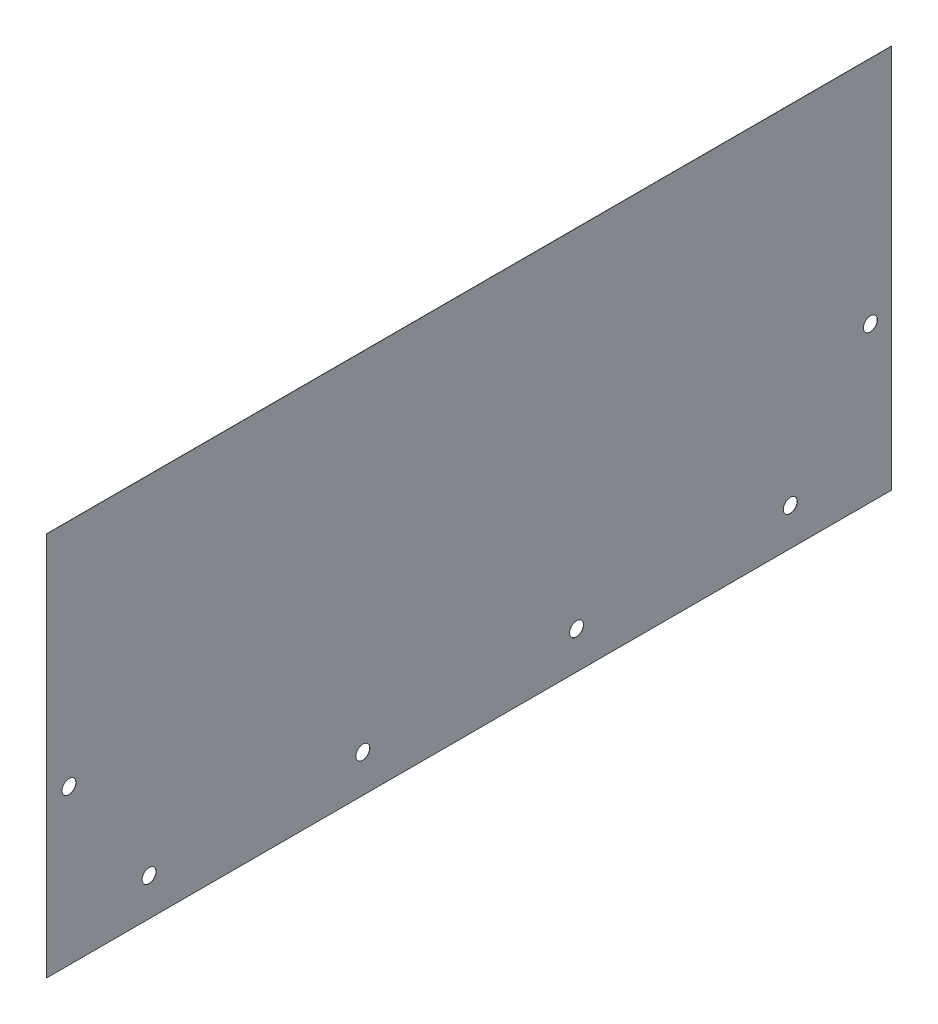
from build123d import *

# Parameters (mm, degrees)
SKETCH1_W                 = 502.3866
SKETCH1_H                 = 809.7266
SIDEPANEL_DEPTH           = 0.127
SKETCH2_R                 = 4.1656
TOPBOTTOMHOLEMASTER_DEPTH = 1.127
LPATTERN1_COUNT           = 4
LPATTERN1_PITCH           = 127.067733333
SKETCH3_R                 = 4.1656
REARHOLESMASTER_DEPTH     = 1.127
LPATTERN2_COUNT           = 4
LPATTERN2_PITCH           = 211.7344
SKETCH4_W                 = 502.3866
SKETCH4_H                 = 581.1266
CUT_EXTRUDE1_DEPTH        = 1.127


with BuildPart() as part:
    # Sketch1 → SidePanel (new body)
    with BuildSketch(Plane(origin=(0, 0, 0), x_dir=(0, 0, -1), z_dir=(1, 0, 0))):
        Rectangle(SKETCH1_W, SKETCH1_H)
    extrude(amount=SIDEPANEL_DEPTH)

    # Sketch2 → TopBottomHoleMaster (cut, through all)
    with BuildSketch(Plane(origin=(0.127, 0, 0), x_dir=(0, 0, -1), z_dir=(1, 0, 0))):
        with Locations((190.9699, -382.6383)):
            Circle(SKETCH2_R)
    topbottomholemaster = extrude(amount=-TOPBOTTOMHOLEMASTER_DEPTH, mode=Mode.SUBTRACT)

    # LPattern1: TopBottomHoleMaster ×4
    with Locations(*[(0, 0, i * LPATTERN1_PITCH) for i in range(1, LPATTERN1_COUNT)]):
        add(topbottomholemaster, mode=Mode.SUBTRACT)

    # Sketch3 → RearHolesMaster (cut, through all)
    with BuildSketch(Plane(origin=(0.127, 0, 0), x_dir=(0, 0, -1), z_dir=(1, 0, 0))):
        with Locations((-237.8583, 322.2117)):
            Circle(SKETCH3_R)
        with Locations((238.5949, 322.2117)):
            Circle(SKETCH3_R)
    rearholesmaster = extrude(amount=-REARHOLESMASTER_DEPTH, mode=Mode.SUBTRACT)

    # LPattern2: RearHolesMaster ×4
    with Locations(*[(0, -i * LPATTERN2_PITCH, 0) for i in range(1, LPATTERN2_COUNT)]):
        add(rearholesmaster, mode=Mode.SUBTRACT)

    # Sketch4 → Cut-Extrude1 (cut, through all)
    with BuildSketch(Plane.ZY):
        with Locations((0, 114.3)):
            Rectangle(SKETCH4_W, SKETCH4_H)
    extrude(amount=-CUT_EXTRUDE1_DEPTH, mode=Mode.SUBTRACT)


solid = part.part
